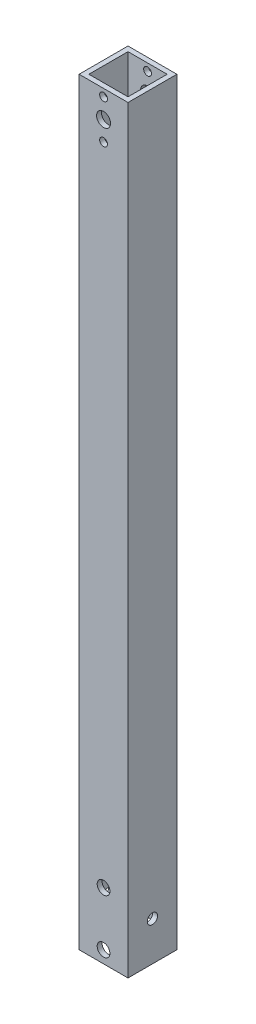
from build123d import *

# Parameters (mm, degrees)
ESBO_O1_W             = 20
ESBO_O1_H             = 20
ESBO_O1_W_2           = 16
ESBO_O1_H_2           = 16
EXTRUS_O_FINA1_DEPTH  = 310
ESBO_O4_R             = 2.85
ESBO_O4_R_2           = 1.6
CORTE_EXTRUS_O2_DEPTH = 21
ESBO_O5_R             = 2.6
CORTE_EXTRUS_O5_DEPTH = 21
ESBO_O6_R             = 2.1
CORTE_EXTRUS_O6_DEPTH = 21


with BuildPart() as part:
    # Esboço1 → Extrusão-Fina1 (new body)
    with BuildSketch(Plane(origin=(0, 0, 0), x_dir=(1, 0, 0), z_dir=(0, 1, 0))):
        with Locations((10, 10)):
            Rectangle(ESBO_O1_W, ESBO_O1_H)
        with Locations((10, 10)):
            Rectangle(ESBO_O1_W_2, ESBO_O1_H_2, mode=Mode.SUBTRACT)
    extrude(amount=EXTRUS_O_FINA1_DEPTH)

    # Esboço4 → Corte-extrusão2 (cut, through all)
    with BuildSketch(Plane.XY):
        with Locations((10, 299)):
            Circle(ESBO_O4_R)
        with Locations((10, 291)):
            Circle(ESBO_O4_R_2)
        with Locations((10, 307)):
            Circle(ESBO_O4_R_2)
    extrude(amount=-CORTE_EXTRUS_O2_DEPTH, mode=Mode.SUBTRACT)

    # Esboço5 → Corte-extrusão5 (cut, through all)
    with BuildSketch(Plane(origin=(0, 0, -20), x_dir=(-1, 0, 0), z_dir=(0, 0, -1))):
        with Locations((-10, 5)):
            Circle(ESBO_O5_R)
        with Locations((-10, 27)):
            Circle(ESBO_O5_R)
    extrude(amount=-CORTE_EXTRUS_O5_DEPTH, mode=Mode.SUBTRACT)

    # Esboço6 → Corte-extrusão6 (cut, through all)
    with BuildSketch(Plane.ZY):
        with Locations((-10, 16)):
            Circle(ESBO_O6_R)
    extrude(amount=-CORTE_EXTRUS_O6_DEPTH, mode=Mode.SUBTRACT)


solid = part.part
